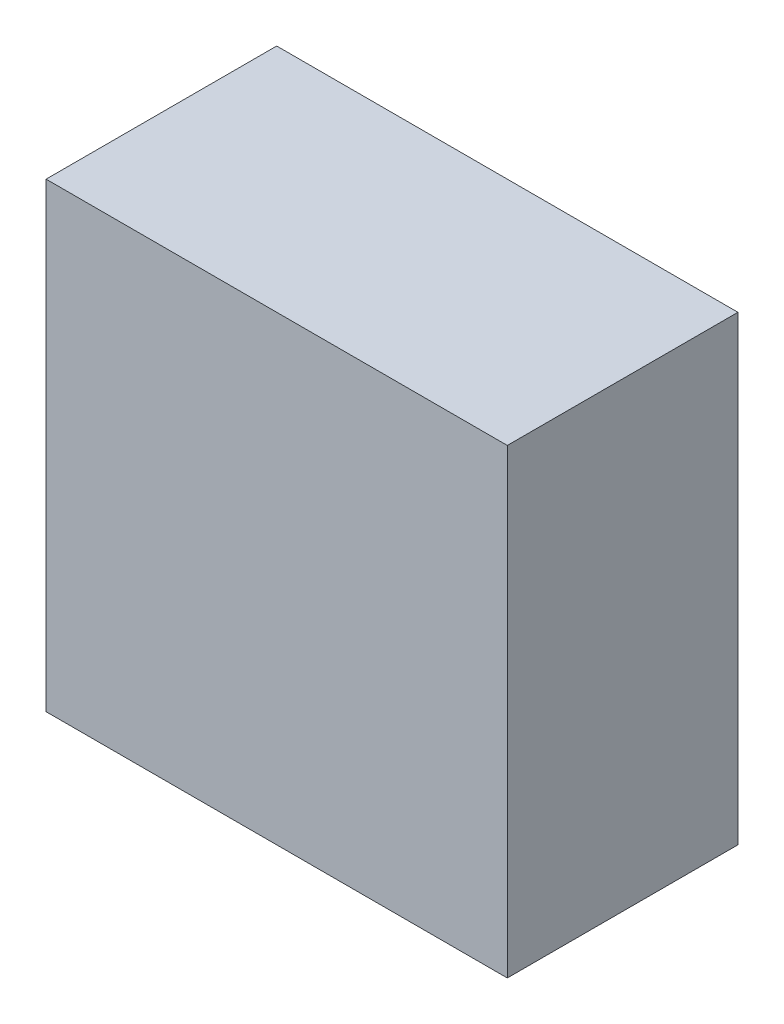
from build123d import *

# Parameters (mm, degrees)
SKETCH1_W           = 25.4
SKETCH1_H           = 25.4
BOSS_EXTRUDE1_DEPTH = 12.7


with BuildPart() as part:
    # Sketch1 → Boss-Extrude1 (new body)
    with BuildSketch(Plane.XY):
        with Locations((12.7, -12.7)):
            Rectangle(SKETCH1_W, SKETCH1_H)
    extrude(amount=BOSS_EXTRUDE1_DEPTH)


solid = part.part
